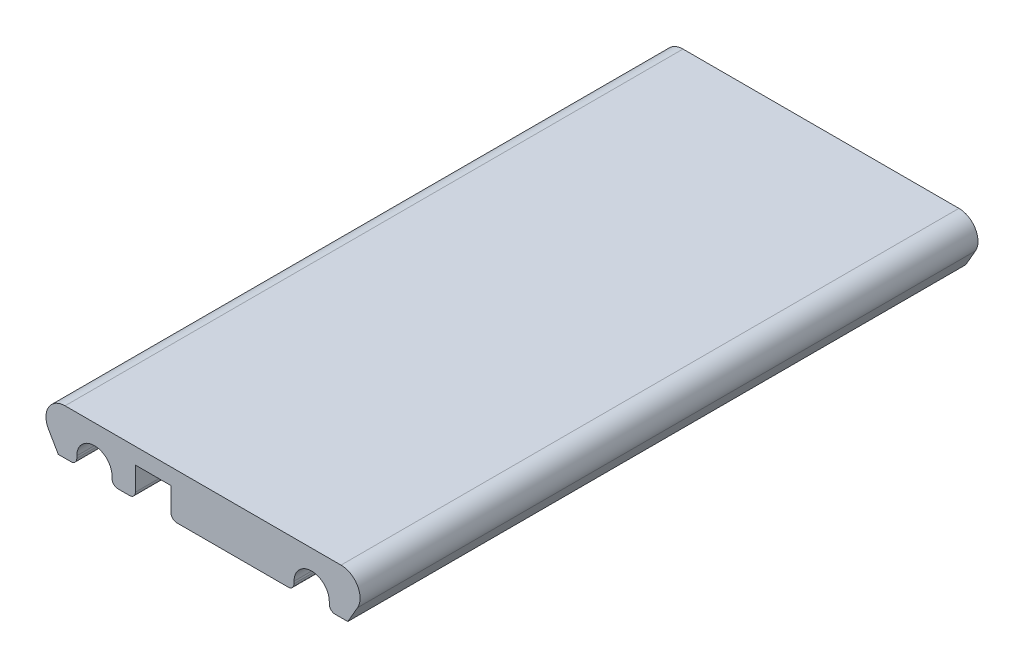
from build123d import *

# Parameters (mm, degrees)
BOSS_EXTRUDE1_DEPTH = 210.5
FILLET1_R           = 2


with BuildPart() as part:
    # Sketch1 → Boss-Extrude1 (new body)
    with BuildSketch(Plane.XY):
        with BuildLine():
            Line((0, 0), (-3.319764048, 5.75))
            ThreePointArc((-3.319764048, 5.75), (-3.319764048, 12.25), (2.309401077, 15.5))
            Line((2.309401077, 15.5), (96.309401077, 15.5))
            ThreePointArc((96.309401077, 15.5), (101.938566201, 12.25), (101.938566201, 5.75))
            Line((101.938566201, 5.75), (98.618802154, 0))
            Line((98.618802154, 0), (92.309401077, 0))
            Line((92.309401077, 0), (92.309401077, 2.75))
            ThreePointArc((92.309401077, 2.75), (86.309401077, 8.75), (80.309401077, 2.75))
            Line((80.309401077, 2.75), (80.309401077, 0))
            Line((80.309401077, 0), (38.359401077, 0))
            Line((38.359401077, 0), (38.359401077, 10))
            Line((38.359401077, 10), (26.259401077, 10))
            Line((26.259401077, 10), (26.259401077, 0))
            Line((26.259401077, 0), (18.309401077, 0))
            Line((18.309401077, 0), (18.309401077, 2.75))
            ThreePointArc((18.309401077, 2.75), (12.309401077, 8.75), (6.309401077, 2.75))
            Line((6.309401077, 2.75), (6.309401077, 0))
            Line((6.309401077, 0), (0, 0))
        make_face()
    extrude(amount=BOSS_EXTRUDE1_DEPTH)

    # Fillet1
    fillet1_edges = [part.edges().sort_by_distance(p)[0] for p in [
        (92.309401077, 0, 105.25),
        (80.309401077, 0, 105.25),
        (38.359401077, 0, 105.25),
        (26.259401077, 0, 105.25),
        (18.309401077, 0, 105.25),
        (6.309401077, 0, 105.25),
    ]]
    fillet(fillet1_edges, radius=FILLET1_R)


solid = part.part
